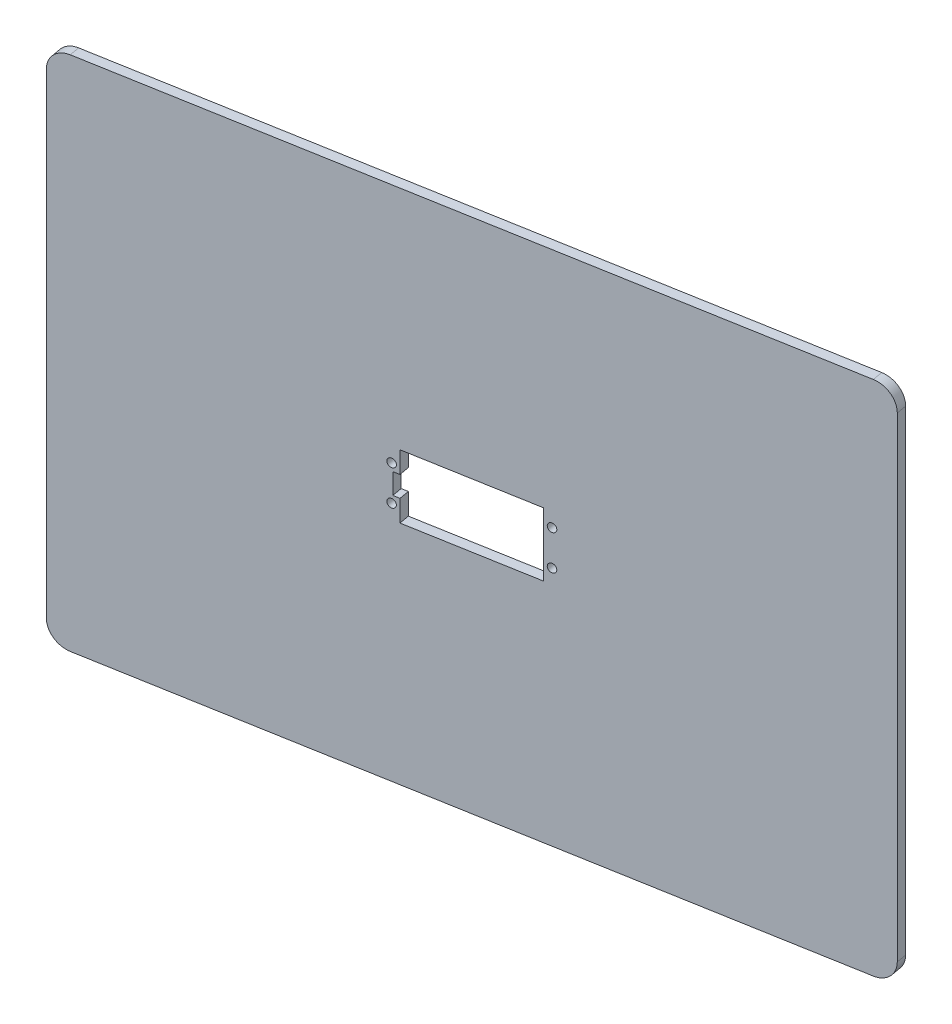
from build123d import *

# Parameters (mm, degrees)
SKETCH1_W           = 355.39931416
SKETCH1_H           = 250
BOSS_EXTRUDE1_DEPTH = 5
CUT_EXTRUDE1_DEPTH  = 10
SKETCH3_R           = 2
CUT_EXTRUDE2_DEPTH  = 5
FILLET1_R           = 10


with BuildPart() as part:
    # Sketch1 → Boss-Extrude1 (new body)
    with BuildSketch(Plane(origin=(-21.339939358, 0, -121.024810115), x_dir=(-0.984807753, 0, 0.173648178), z_dir=(-0.173648178, 0, -0.984807753))):
        with Locations((-4.932202266, -11.228757924)):
            Rectangle(SKETCH1_W, SKETCH1_H)
    extrude(amount=BOSS_EXTRUDE1_DEPTH)

    # Sketch2 → Cut-Extrude1 (cut)
    with BuildSketch(Plane(origin=(-21.339939358, 0, -121.024810115), x_dir=(0.984807753, 0, -0.173648178), z_dir=(0.173648178, 0, 0.984807753))):
        Polygon((-25.067797734, -16.228757924), (-25.067797734, -26.578757924), (34.932202266, -26.578757924), (34.932202266, 4.121242076), (-25.067797734, 4.121242076), (-25.067797734, -6.228757924), (-28.067797734, -6.228757924), (-28.067797734, -16.228757924), align=None)
    extrude(amount=-CUT_EXTRUDE1_DEPTH, mode=Mode.SUBTRACT)

    # Sketch3 → Cut-Extrude2 (cut)
    with BuildSketch(Plane(origin=(-22.208180247, 0, -125.94884888), x_dir=(-0.984807753, 0, 0.173648178), z_dir=(-0.173648178, 0, -0.984807753))):
        with Locations((28.567797734, -19.678757924)):
            Circle(SKETCH3_R)
        with Locations((28.567797734, -2.778757924)):
            Circle(SKETCH3_R)
        with Locations((-38.432202266, -2.778757924)):
            Circle(SKETCH3_R)
        with Locations((-38.432202266, -19.678757924)):
            Circle(SKETCH3_R)
    extrude(amount=-CUT_EXTRUDE2_DEPTH, mode=Mode.SUBTRACT)

    # Fillet1
    fillet1_edges = [part.edges().sort_by_distance(p)[0] for p in [
        (158.083211229, 113.771242076, -155.200519056),
        (-191.916788771, 113.771242076, -93.486075809),
        (-191.916788771, -136.228757924, -93.486075809),
        (158.083211229, -136.228757924, -155.200519056),
    ]]
    fillet(fillet1_edges, radius=FILLET1_R)


solid = part.part
